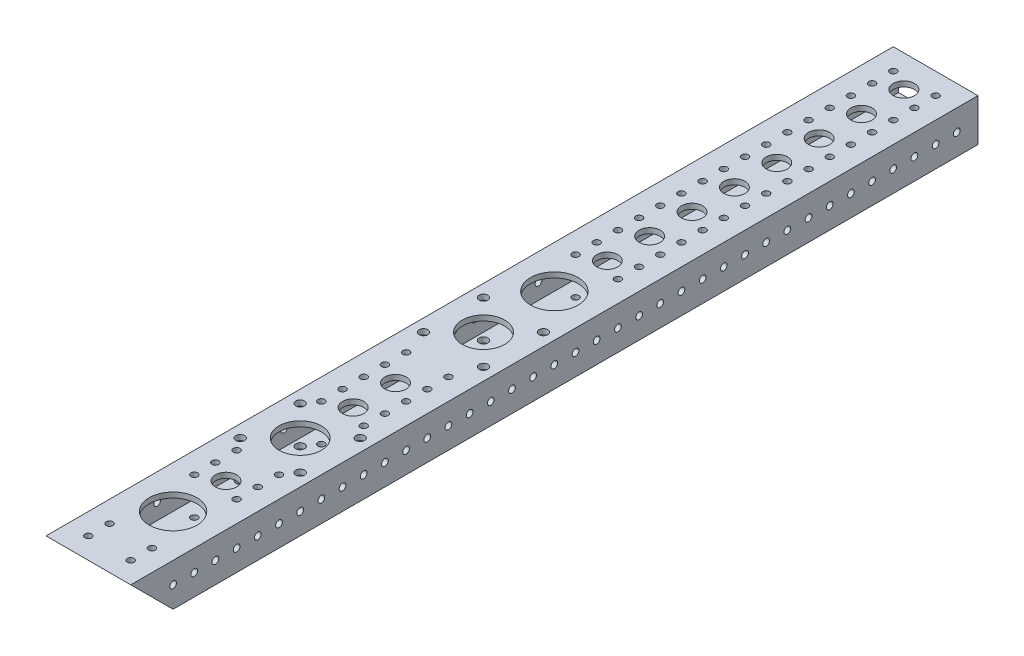
from build123d import *

# Parameters (mm, degrees)
SKETCH1_W                = 50.8
SKETCH1_H                = 25.4
SKETCH1_W_2              = 44.45
SKETCH1_H_2              = 19.05
BOSS_EXTRUDE1_DEPTH      = 508
SKETCH2_R                = 2.0193
SKETCH2_R_2              = 6.35
CUT_EXTRUDE1_DEPTH       = 63.5
SKETCH3_R                = 2.0193
CUT_EXTRUDE2_DEPTH       = 63.5
F_1_125_DIAMETER_HOLE1_D = 28.575
SKETCH7_R                = 12.7
SKETCH7_R_2              = 2.6289
CUT_EXTRUDE3_DEPTH       = 26.4
CUT_EXTRUDE4_DEPTH       = 51.8
CUT_EXTRUDE5_REACH       = 27.4
SKETCH10_R               = 2.0193


with BuildPart() as part:
    # Sketch1 → Boss-Extrude1 (new body)
    with BuildSketch(Plane.XY):
        with Locations((25.4, 12.7)):
            Rectangle(SKETCH1_W, SKETCH1_H)
        with Locations((25.4, 12.7)):
            Rectangle(SKETCH1_W_2, SKETCH1_H_2, mode=Mode.SUBTRACT)
    extrude(amount=BOSS_EXTRUDE1_DEPTH)

    # Sketch2 → Cut-Extrude1 (cut)
    with BuildSketch(Plane(origin=(0, 25.4, 0), x_dir=(1, 0, 0), z_dir=(0, 1, 0))):
        with Locations((12.7, -495.3)):
            Circle(SKETCH2_R)
        with Locations((38.1, -495.3)):
            Circle(SKETCH2_R)
        with Locations((12.7, -431.8)):
            Circle(SKETCH2_R)
        with Locations((38.1, -431.8)):
            Circle(SKETCH2_R)
        with Locations((12.7, -419.1)):
            Circle(SKETCH2_R)
        with Locations((38.1, -419.1)):
            Circle(SKETCH2_R)
        with Locations((12.7, -406.4)):
            Circle(SKETCH2_R)
        with Locations((38.1, -406.4)):
            Circle(SKETCH2_R)
        with Locations((12.7, -355.6)):
            Circle(SKETCH2_R)
        with Locations((38.1, -355.6)):
            Circle(SKETCH2_R)
        with Locations((12.7, -342.9)):
            Circle(SKETCH2_R)
        with Locations((38.1, -342.9)):
            Circle(SKETCH2_R)
        with Locations((12.7, -330.2)):
            Circle(SKETCH2_R)
        with Locations((38.1, -330.2)):
            Circle(SKETCH2_R)
        with Locations((12.7, -317.5)):
            Circle(SKETCH2_R)
        with Locations((38.1, -317.5)):
            Circle(SKETCH2_R)
        with Locations((12.7, -304.8)):
            Circle(SKETCH2_R)
        with Locations((38.1, -304.8)):
            Circle(SKETCH2_R)
        with Locations((12.7, -203.2)):
            Circle(SKETCH2_R)
        with Locations((38.1, -203.2)):
            Circle(SKETCH2_R)
        with Locations((12.7, -190.5)):
            Circle(SKETCH2_R)
        with Locations((38.1, -190.5)):
            Circle(SKETCH2_R)
        with Locations((12.7, -177.8)):
            Circle(SKETCH2_R)
        with Locations((38.1, -177.8)):
            Circle(SKETCH2_R)
        with Locations((12.7, -165.1)):
            Circle(SKETCH2_R)
        with Locations((38.1, -165.1)):
            Circle(SKETCH2_R)
        with Locations((12.7, -152.4)):
            Circle(SKETCH2_R)
        with Locations((38.1, -152.4)):
            Circle(SKETCH2_R)
        with Locations((12.7, -139.7)):
            Circle(SKETCH2_R)
        with Locations((38.1, -139.7)):
            Circle(SKETCH2_R)
        with Locations((12.7, -127)):
            Circle(SKETCH2_R)
        with Locations((38.1, -127)):
            Circle(SKETCH2_R)
        with Locations((12.7, -114.3)):
            Circle(SKETCH2_R)
        with Locations((38.1, -114.3)):
            Circle(SKETCH2_R)
        with Locations((12.7, -101.6)):
            Circle(SKETCH2_R)
        with Locations((38.1, -101.6)):
            Circle(SKETCH2_R)
        with Locations((12.7, -88.9)):
            Circle(SKETCH2_R)
        with Locations((38.1, -88.9)):
            Circle(SKETCH2_R)
        with Locations((12.7, -76.2)):
            Circle(SKETCH2_R)
        with Locations((38.1, -76.2)):
            Circle(SKETCH2_R)
        with Locations((12.7, -63.5)):
            Circle(SKETCH2_R)
        with Locations((38.1, -63.5)):
            Circle(SKETCH2_R)
        with Locations((12.7, -50.8)):
            Circle(SKETCH2_R)
        with Locations((38.1, -50.8)):
            Circle(SKETCH2_R)
        with Locations((12.7, -38.1)):
            Circle(SKETCH2_R)
        with Locations((38.1, -38.1)):
            Circle(SKETCH2_R)
        with Locations((12.7, -25.4)):
            Circle(SKETCH2_R)
        with Locations((38.1, -25.4)):
            Circle(SKETCH2_R)
        with Locations((12.7, -12.7)):
            Circle(SKETCH2_R)
        with Locations((38.1, -12.7)):
            Circle(SKETCH2_R)
        with Locations((25.4, -19.05)):
            Circle(SKETCH2_R_2)
        with Locations((25.4, -44.45)):
            Circle(SKETCH2_R_2)
        with Locations((25.4, -69.85)):
            Circle(SKETCH2_R_2)
        with Locations((25.4, -95.25)):
            Circle(SKETCH2_R_2)
        with Locations((25.4, -120.65)):
            Circle(SKETCH2_R_2)
        with Locations((25.4, -146.05)):
            Circle(SKETCH2_R_2)
        with Locations((25.4, -171.45)):
            Circle(SKETCH2_R_2)
        with Locations((25.4, -196.85)):
            Circle(SKETCH2_R_2)
        with Locations((25.4, -323.85)):
            Circle(SKETCH2_R_2)
        with Locations((25.4, -349.25)):
            Circle(SKETCH2_R_2)
        with Locations((25.4, -425.45)):
            Circle(SKETCH2_R_2)
    extrude(amount=-CUT_EXTRUDE1_DEPTH, mode=Mode.SUBTRACT)

    # Sketch3 → Cut-Extrude2 (cut)
    with BuildSketch(Plane(origin=(50.8, 0, 0), x_dir=(0, 0, -1), z_dir=(1, 0, 0))):
        with Locations((-482.6, 12.7)):
            Circle(SKETCH3_R)
        with Locations((-469.9, 12.7)):
            Circle(SKETCH3_R)
        with Locations((-457.2, 12.7)):
            Circle(SKETCH3_R)
        with Locations((-444.5, 12.7)):
            Circle(SKETCH3_R)
        with Locations((-431.8, 12.7)):
            Circle(SKETCH3_R)
        with Locations((-419.1, 12.7)):
            Circle(SKETCH3_R)
        with Locations((-406.4, 12.7)):
            Circle(SKETCH3_R)
        with Locations((-393.7, 12.7)):
            Circle(SKETCH3_R)
        with Locations((-381, 12.7)):
            Circle(SKETCH3_R)
        with Locations((-368.3, 12.7)):
            Circle(SKETCH3_R)
        with Locations((-355.6, 12.7)):
            Circle(SKETCH3_R)
        with Locations((-342.9, 12.7)):
            Circle(SKETCH3_R)
        with Locations((-330.2, 12.7)):
            Circle(SKETCH3_R)
        with Locations((-317.5, 12.7)):
            Circle(SKETCH3_R)
        with Locations((-304.8, 12.7)):
            Circle(SKETCH3_R)
        with Locations((-292.1, 12.7)):
            Circle(SKETCH3_R)
        with Locations((-279.4, 12.7)):
            Circle(SKETCH3_R)
        with Locations((-266.7, 12.7)):
            Circle(SKETCH3_R)
        with Locations((-254, 12.7)):
            Circle(SKETCH3_R)
        with Locations((-241.3, 12.7)):
            Circle(SKETCH3_R)
        with Locations((-228.6, 12.7)):
            Circle(SKETCH3_R)
        with Locations((-215.9, 12.7)):
            Circle(SKETCH3_R)
        with Locations((-203.2, 12.7)):
            Circle(SKETCH3_R)
        with Locations((-190.5, 12.7)):
            Circle(SKETCH3_R)
        with Locations((-177.8, 12.7)):
            Circle(SKETCH3_R)
        with Locations((-165.1, 12.7)):
            Circle(SKETCH3_R)
        with Locations((-152.4, 12.7)):
            Circle(SKETCH3_R)
        with Locations((-139.7, 12.7)):
            Circle(SKETCH3_R)
        with Locations((-127, 12.7)):
            Circle(SKETCH3_R)
        with Locations((-114.3, 12.7)):
            Circle(SKETCH3_R)
        with Locations((-101.6, 12.7)):
            Circle(SKETCH3_R)
        with Locations((-88.9, 12.7)):
            Circle(SKETCH3_R)
        with Locations((-76.2, 12.7)):
            Circle(SKETCH3_R)
        with Locations((-63.5, 12.7)):
            Circle(SKETCH3_R)
        with Locations((-50.8, 12.7)):
            Circle(SKETCH3_R)
        with Locations((-38.1, 12.7)):
            Circle(SKETCH3_R)
        with Locations((-25.4, 12.7)):
            Circle(SKETCH3_R)
        with Locations((-12.7, 12.7)):
            Circle(SKETCH3_R)
    extrude(amount=-CUT_EXTRUDE2_DEPTH, mode=Mode.SUBTRACT)

    # F (1.125) Diameter Hole1 (through all)
    with Locations(Plane(origin=(0, 25.4, 0), x_dir=(1, 0, 0), z_dir=(0, 1, 0))):
        with Locations((25.4, -228.6), (25.4, -457.2)):
            Hole(F_1_125_DIAMETER_HOLE1_D / 2)

    # Sketch7 → Cut-Extrude3 (cut, through all)
    with BuildSketch(Plane(origin=(0, 25.4, 0), x_dir=(1, 0, 0), z_dir=(0, 1, 0))):
        with Locations((25.4, -381)):
            Circle(SKETCH7_R)
        with Locations((43.360512242, -363.039487758)):
            Circle(SKETCH7_R_2)
        with Locations((43.360512242, -398.960512242)):
            Circle(SKETCH7_R_2)
        with Locations((7.439487758, -398.960512242)):
            Circle(SKETCH7_R_2)
        with Locations((7.439487758, -363.039487758)):
            Circle(SKETCH7_R_2)
        with Locations((25.4, -271.0942)):
            Circle(SKETCH7_R)
        with Locations((43.360512242, -253.133687758)):
            Circle(SKETCH7_R_2)
        with Locations((43.360512242, -289.054712242)):
            Circle(SKETCH7_R_2)
        with Locations((7.439487758, -289.054712242)):
            Circle(SKETCH7_R_2)
        with Locations((7.439487758, -253.133687758)):
            Circle(SKETCH7_R_2)
    extrude(amount=-CUT_EXTRUDE3_DEPTH, mode=Mode.SUBTRACT)

    # Sketch8 → Cut-Extrude4 (cut, through all)
    with BuildSketch(Plane.ZY):
        Polygon((508, 25.4), (482.6, 0), (508, 0), align=None)
    extrude(amount=-CUT_EXTRUDE4_DEPTH, mode=Mode.SUBTRACT)

    # Sketch10 → Cut-Extrude5 (cut, up to next)
    with BuildSketch(Plane(origin=(0, 25.4, 0), x_dir=(1, 0, 0), z_dir=(0, 1, 0)), mode=Mode.PRIVATE) as cut_extrude5_sk1:
        with Locations((38.1, -482.6)):
            Circle(SKETCH10_R)
    cut_extrude5_tool1 = extrude(cut_extrude5_sk1.sketch, amount=-CUT_EXTRUDE5_REACH, mode=Mode.PRIVATE) & part.part
    add(cut_extrude5_tool1.solids().sort_by_distance((38.1, 25.4, 482.6))[0], mode=Mode.SUBTRACT)
    # Sketch10 → Cut-Extrude5 (cut, up to next)
    with BuildSketch(Plane(origin=(0, 25.4, 0), x_dir=(1, 0, 0), z_dir=(0, 1, 0)), mode=Mode.PRIVATE) as cut_extrude5_sk2:
        with Locations((12.7, -482.6)):
            Circle(SKETCH10_R)
    cut_extrude5_tool2 = extrude(cut_extrude5_sk2.sketch, amount=-CUT_EXTRUDE5_REACH, mode=Mode.PRIVATE) & part.part
    add(cut_extrude5_tool2.solids().sort_by_distance((12.7, 25.4, 482.6))[0], mode=Mode.SUBTRACT)


solid = part.part
